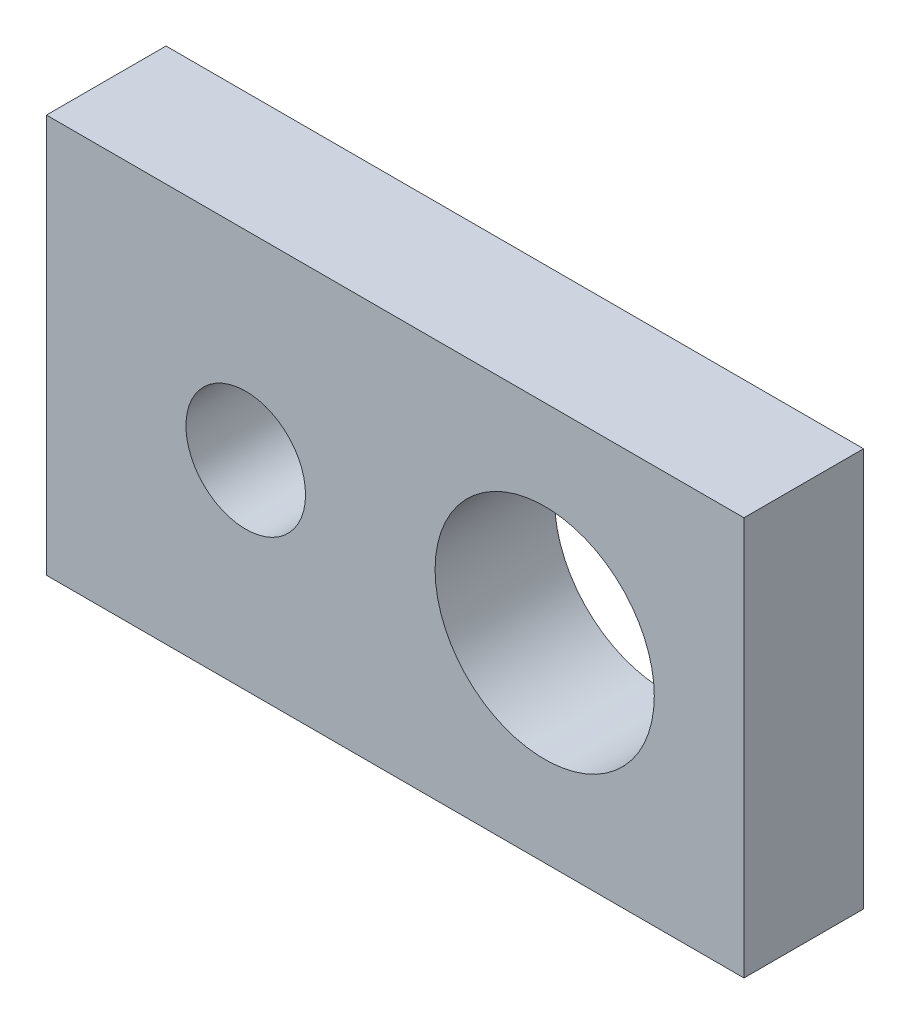
from build123d import *

# Parameters (mm, degrees)
SKETCH1_W           = 35
SKETCH1_H           = 20
SKETCH1_R           = 3
SKETCH1_R_2         = 5.5
BOSS_EXTRUDE1_DEPTH = 6


with BuildPart() as part:
    # Sketch1 → Boss-Extrude1 (new body)
    with BuildSketch(Plane.XY):
        Rectangle(SKETCH1_W, SKETCH1_H)
        with Locations((-7.5, 0)):
            Circle(SKETCH1_R, mode=Mode.SUBTRACT)
        with Locations((7.5, 0)):
            Circle(SKETCH1_R_2, mode=Mode.SUBTRACT)
    extrude(amount=BOSS_EXTRUDE1_DEPTH)


solid = part.part
